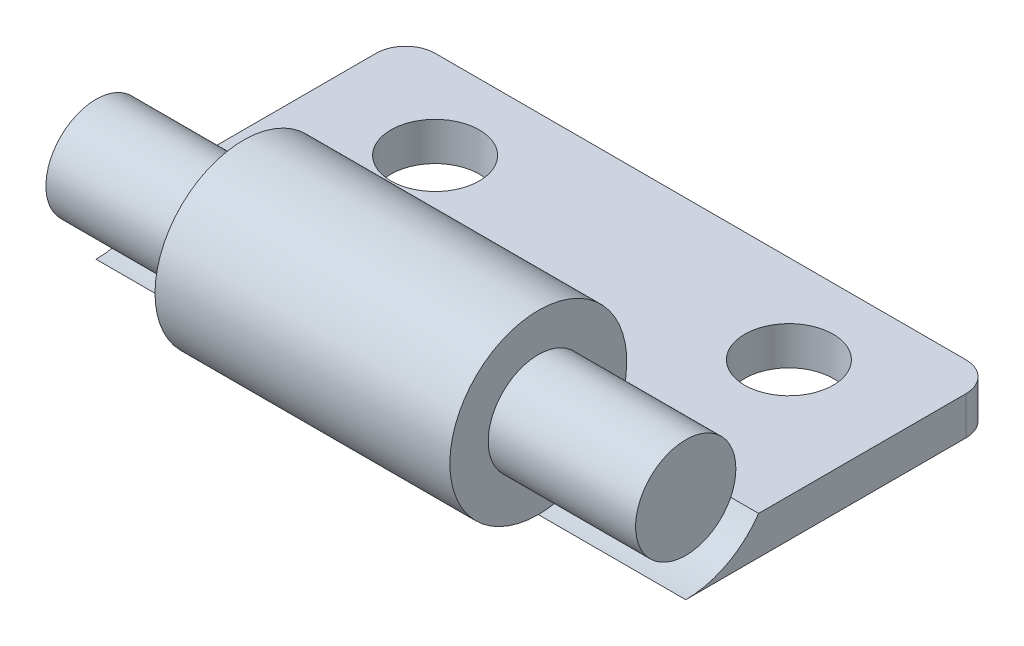
from build123d import *

# Parameters (mm, degrees)
SKETCH_1_W          = 10.5
SKETCH_1_H          = 1.3
EXTRUDE_1_DEPTH     = 10
SKETCH_2_R          = 3
CUT_EXTRUDE_1_DEPTH = 5
SKETCH_3_R          = 3
EXTRUDE_2_DEPTH     = 10
SKETCH_4_R          = 1.7
EXTRUDE_3_DEPTH     = 5
SKETCH_5_R          = 1.5
CUT_EXTRUDE_2_DEPTH = 5
FILLET_1_R          = 1


with BuildPart() as part:
    # 草图1 → 凸台-拉伸1 (new body, symmetric)
    with BuildSketch(Plane(origin=(0, 0, 0), x_dir=(0, 0, -1), z_dir=(1, 0, 0))):
        with Locations((5.25, 0.65)):
            Rectangle(SKETCH_1_W, SKETCH_1_H)
    extrude(amount=EXTRUDE_1_DEPTH, both=True)

    # 草图2 → 切除-拉伸1 (cut)
    with BuildSketch(Plane(origin=(10, 0, 0), x_dir=(0, 0, -1), z_dir=(1, 0, 0))):
        with Locations((0, 3)):
            Circle(SKETCH_2_R)
    cut_extrude_1 = extrude(amount=-CUT_EXTRUDE_1_DEPTH, mode=Mode.SUBTRACT)

    # 草图3 → 凸台-拉伸2 (add)
    with BuildSketch(Plane(origin=(5, 0, 0), x_dir=(0, 0, -1), z_dir=(1, 0, 0))):
        with Locations((0, 3)):
            Circle(SKETCH_3_R)
    extrude(amount=-EXTRUDE_2_DEPTH)

    # 草图4 → 凸台-拉伸3 (add)
    with BuildSketch(Plane(origin=(5, 0, 0), x_dir=(0, 0, -1), z_dir=(1, 0, 0))):
        with Locations((0, 3)):
            Circle(SKETCH_4_R)
    extrude_3 = extrude(amount=EXTRUDE_3_DEPTH)

    # 镜向1: 切除-拉伸1, 凸台-拉伸3 across plane
    add(cut_extrude_1.mirror(Plane(origin=(0, 0, 0), x_dir=(0, 0, 1), z_dir=(1, 0, 0))), mode=Mode.SUBTRACT)
    add(extrude_3.mirror(Plane(origin=(0, 0, 0), x_dir=(0, 0, 1), z_dir=(1, 0, 0))))

    # 草图5 → 切除-拉伸2 (cut)
    with BuildSketch(Plane(origin=(0, 1.3, 0), x_dir=(1, 0, 0), z_dir=(0, 1, 0))):
        with Locations((-6, 7.5)):
            Circle(SKETCH_5_R)
    cut_extrude_2 = extrude(amount=-CUT_EXTRUDE_2_DEPTH, mode=Mode.SUBTRACT)

    # 镜向2: 切除-拉伸2 across plane
    add(cut_extrude_2.mirror(Plane(origin=(0, 0, 0), x_dir=(0, 0, 1), z_dir=(1, 0, 0))), mode=Mode.SUBTRACT)

    # 圆角1
    fillet_1_edges = [part.edges().sort_by_distance(p)[0] for p in [
        (10, 0.65, -10.5),
        (-10, 0.65, -10.5),
    ]]
    fillet(fillet_1_edges, radius=FILLET_1_R)


solid = part.part
